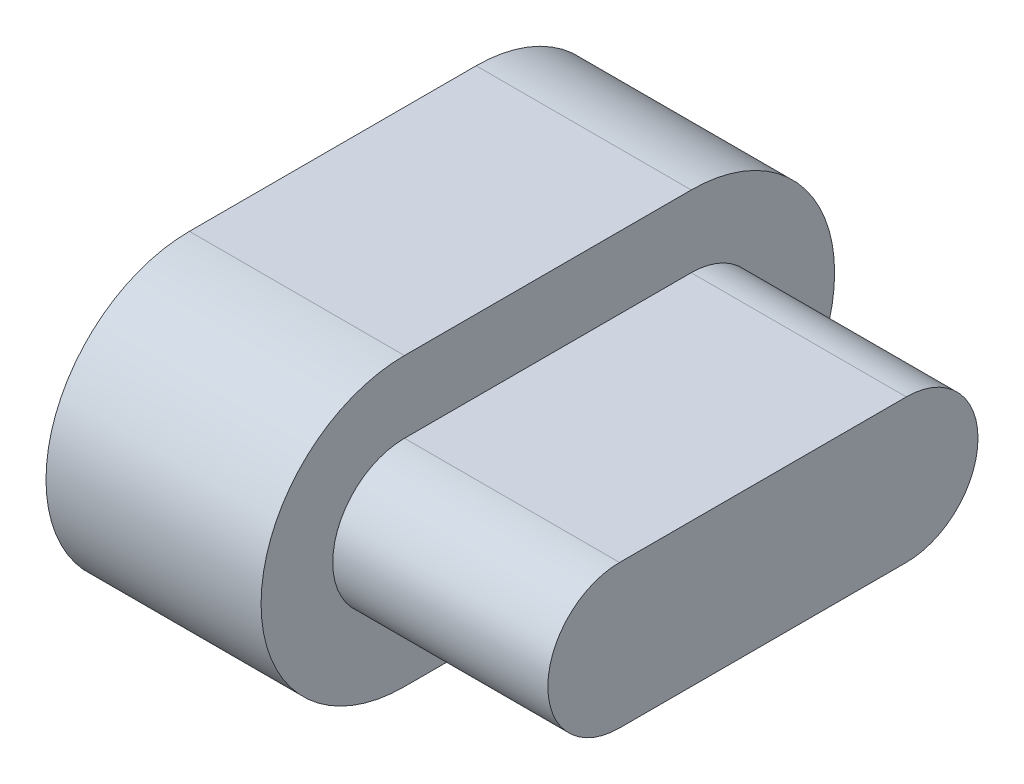
from build123d import *

# Parameters (mm, degrees)
EXTRUDE_1_DEPTH = 3
EXTRUDE_2_DEPTH = 3


with BuildPart() as part:
    # 草图1 → 凸台-拉伸1 (new body)
    with BuildSketch(Plane(origin=(0, 0, 0), x_dir=(0, 0, -1), z_dir=(1, 0, 0))):
        with BuildLine():
            Line((-2, 2), (2, 2))
            ThreePointArc((2, 2), (4, 0), (2, -2))
            Line((2, -2), (-2, -2))
            ThreePointArc((-2, -2), (-4, 0), (-2, 2))
        make_face()
    extrude(amount=EXTRUDE_1_DEPTH)

    # 草图2 → 凸台-拉伸2 (add)
    with BuildSketch(Plane(origin=(3, 0, 0), x_dir=(0, 0, -1), z_dir=(1, 0, 0))):
        with BuildLine():
            Line((-2, -1), (2, -1))
            ThreePointArc((2, -1), (3, 0), (2, 1))
            Line((2, 1), (-2, 1))
            ThreePointArc((-2, 1), (-3, 0), (-2, -1))
        make_face()
    extrude(amount=EXTRUDE_2_DEPTH)


solid = part.part
